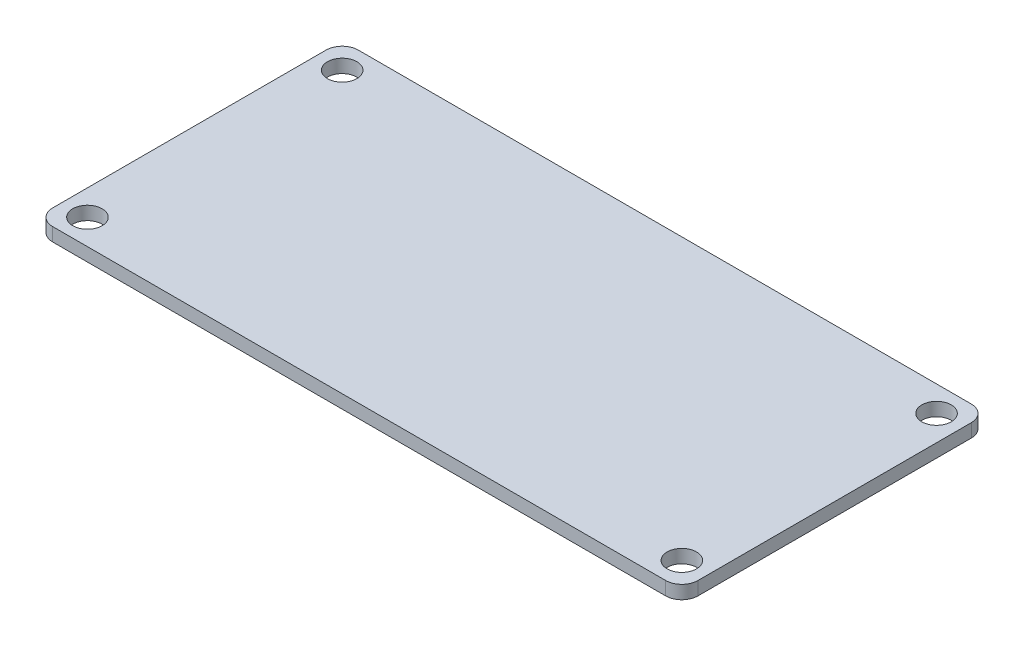
from build123d import *

# Parameters (mm, degrees)
SKETCH1_W               = 48.26
SKETCH1_H               = 22.86
BOSS_EXTRUDE1_DEPTH     = 1
SKETCH2_R               = 1.09982
CUT_EXTRUDE1_DEPTH      = 1
CUT_EXTRUDE1_DEPTH_BACK = 2
FILLET1_R               = 1.2065
SKETCH3_W               = 6.1
SKETCH3_H               = 8
BOSS_EXTRUDE2_DEPTH     = 3.5


with BuildPart() as part:
    # Sketch1 → Boss-Extrude1 (new body)
    with BuildSketch(Plane(origin=(0, 0, 0), x_dir=(1, 0, 0), z_dir=(0, 1, 0))):
        with Locations((24.13, 11.43)):
            Rectangle(SKETCH1_W, SKETCH1_H)
    extrude(amount=BOSS_EXTRUDE1_DEPTH)

    # Sketch2 → Cut-Extrude1 (cut, two sides)
    with BuildSketch(Plane(origin=(0, 1, 0), x_dir=(1, 0, 0), z_dir=(0, 1, 0))) as cut_extrude1_sk:
        with Locations((1.905, 20.955)):
            Circle(SKETCH2_R)
        with Locations((1.905, 1.905)):
            Circle(SKETCH2_R)
        with Locations((46.355, 1.905)):
            Circle(SKETCH2_R)
        with Locations((46.355, 20.955)):
            Circle(SKETCH2_R)
    extrude(amount=CUT_EXTRUDE1_DEPTH, mode=Mode.SUBTRACT)
    extrude(cut_extrude1_sk.sketch, amount=-CUT_EXTRUDE1_DEPTH_BACK, mode=Mode.SUBTRACT)

    # Fillet1
    fillet1_edges = [part.edges().sort_by_distance(p)[0] for p in [
        (0, 0.5, -22.86),
        (48.26, 0.5, -22.86),
        (48.26, 0.5, 0),
        (0, 0.5, 0),
    ]]
    fillet(fillet1_edges, radius=FILLET1_R)

    # Sketch3 → Boss-Extrude2 (add)
    with BuildSketch(Plane.XZ):
        with Locations((2.05, -11.43)):
            Rectangle(SKETCH3_W, SKETCH3_H)
    extrude(amount=BOSS_EXTRUDE2_DEPTH)


solid = part.part
